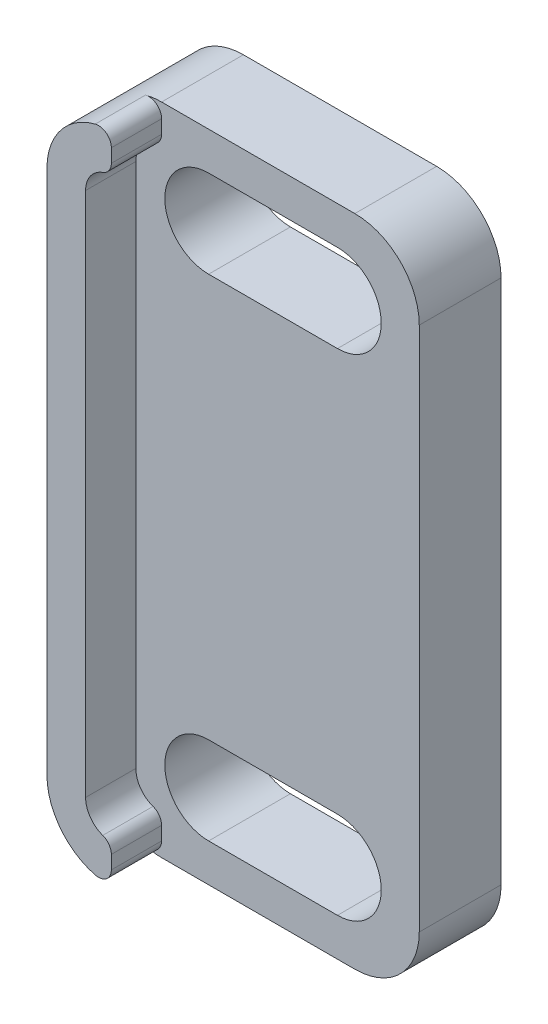
from build123d import *

# Parameters (mm, degrees)
SKETCH1_W           = 12.500000000000002
SKETCH1_H           = 25.399999999999995
BOSS_EXTRUDE1_DEPTH = 3.175
FILLET1_R           = 2.5
BOSS_EXTRUDE2_START = 1.95
BOSS_EXTRUDE2_DEPTH = 1.95
FILLET2_R           = 0.5


with BuildPart() as part:
    # Sketch1 → Boss-Extrude1 (new body)
    with BuildSketch(Plane.XY):
        with Locations((6.250000000000001, 12.699999999999998)):
            Rectangle(SKETCH1_W, SKETCH1_H)
        with BuildLine():
            Line((4.325, 4.875000000000003), (9.325, 4.874999999999999))
            ThreePointArc((9.325, 4.874999999999999), (11.025, 3.1750000000000007), (9.325, 1.474999999999999))
            Line((9.325, 1.474999999999999), (4.325, 1.4750000000000023))
            ThreePointArc((4.325, 1.4750000000000023), (2.625, 3.1750000000000025), (4.325, 4.875000000000003))
        make_face(mode=Mode.SUBTRACT)
        with BuildLine():
            Line((4.325, 23.925000000000004), (9.325, 23.925000000000004))
            ThreePointArc((9.325, 23.925000000000004), (11.025000000000002, 22.225), (9.325, 20.525))
            Line((9.325, 20.525), (4.325, 20.525))
            ThreePointArc((4.325, 20.525), (2.624999999999994, 22.224999999999998), (4.325, 23.925000000000004))
        make_face(mode=Mode.SUBTRACT)
    extrude(amount=BOSS_EXTRUDE1_DEPTH)

    # Fillet1
    fillet1_edges = [part.edges().sort_by_distance(p)[0] for p in [
        (0, 25.4, 1.5875),
        (12.5, 25.4, 1.5875),
        (12.5, 0, 1.5875),
        (0, 0, 1.5875),
    ]]
    fillet(fillet1_edges, radius=FILLET1_R)

    # Sketch2 → Boss-Extrude2 (add)
    with BuildSketch(Plane.XY.offset(3.175).offset(BOSS_EXTRUDE2_START)):
        with BuildLine():
            Line((0, 22.9), (0, 2.5))
            ThreePointArc((0, 2.5), (0.7322330470336307, 0.7322330470336313), (2.5, 0))
            Line((2.5, 0), (2.5, 1.5))
            ThreePointArc((2.5, 1.5), (1.7928932188134532, 1.7928932188134517), (1.5, 2.4999999999999987))
            Line((1.5, 2.4999999999999987), (1.5000000000000004, 22.9))
            ThreePointArc((1.5000000000000004, 22.9), (1.7928932188134499, 23.60710678118655), (2.5, 23.900000000000002))
            Line((2.5, 23.900000000000002), (2.5, 25.4))
            ThreePointArc((2.5, 25.4), (0.7322330470336313, 24.667766952966367), (0, 22.9))
        make_face()
    extrude(amount=-BOSS_EXTRUDE2_DEPTH)

    # Fillet2
    fillet2_edges = [part.edges().sort_by_distance(p)[0] for p in [
        (2.5, 25.4, 4.15),
        (2.5, 0, 4.15),
        (2.5, 1.5000000000000002, 4.15),
        (2.5, 23.900000000000002, 4.15),
    ]]
    fillet(fillet2_edges, radius=FILLET2_R)


solid = part.part
